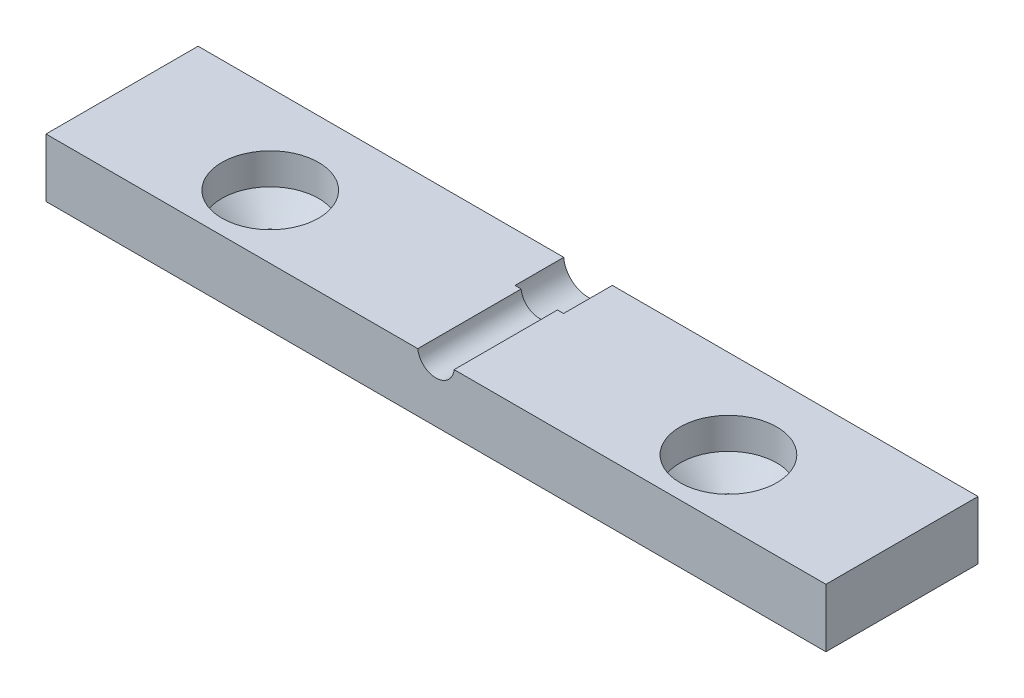
from build123d import *

# Parameters (mm, degrees)
SKETCH1_W                                    = 101.6
SKETCH1_H                                    = 19.812
BOSS_EXTRUDE1_DEPTH                          = 3.81
CSK_FOR_M6_COUNTERSUNK_FLAT_HEAD_SCR_2_COUNT = 2
CSK_FOR_M6_COUNTERSUNK_FLAT_HEAD_SCR_2_PITCH = 59.69
SKETCH5_W                                    = 101.6
SKETCH5_H                                    = 19.812
SKETCH5_R                                    = 6.3
BOSS_EXTRUDE2_DEPTH                          = 3.81
SKETCH6_R                                    = 3.175
CUT_EXTRUDE1_DEPTH                           = 6.35
CUT_EXTRUDE2_DEPTH                           = 7.35
CUT_EXTRUDE2_DEPTH_BACK                      = 14.462


with BuildPart() as part:
    # Sketch1 → Boss-Extrude1 (new body)
    with BuildSketch(Plane(origin=(0, 0, 0), x_dir=(1, 0, 0), z_dir=(0, 1, 0))):
        Rectangle(SKETCH1_W, SKETCH1_H)
    extrude(amount=BOSS_EXTRUDE1_DEPTH)

    # Sketch4 → CSK for M6 Countersunk Flat Head Screw1 (revolve, cut)
    with BuildSketch(Plane(origin=(-29.845, 3.81, 1.651), x_dir=(0, 0, 1), z_dir=(1, 0, 0))):
        Polygon((0, 0), (0, 3.81), (3.5, 3.81), (3.5, 3.054), (6.3, 0.254), (6.3, 0), align=None)
    csk_for_m6_countersunk_flat_head_screw1 = revolve(axis=Axis((-29.845, 10.16, 1.651), (0, -1, 0)), mode=Mode.SUBTRACT)

    # CSK for M6 Countersunk Flat Head Scr 2: CSK for M6 Countersunk Flat Head Screw1 ×2
    with Locations(*[(i * CSK_FOR_M6_COUNTERSUNK_FLAT_HEAD_SCR_2_PITCH, 0, 0) for i in range(1, CSK_FOR_M6_COUNTERSUNK_FLAT_HEAD_SCR_2_COUNT)]):
        add(csk_for_m6_countersunk_flat_head_screw1, mode=Mode.SUBTRACT)

    # Sketch5 → Boss-Extrude2 (add)
    with BuildSketch(Plane(origin=(0, 3.81, 0), x_dir=(1, 0, 0), z_dir=(0, 1, 0))):
        Rectangle(SKETCH5_W, SKETCH5_H)
        with Locations((-29.845, -1.651)):
            Circle(SKETCH5_R, mode=Mode.SUBTRACT)
        with Locations((29.845, -1.651)):
            Circle(SKETCH5_R, mode=Mode.SUBTRACT)
    extrude(amount=BOSS_EXTRUDE2_DEPTH)

    # Sketch6 → Cut-Extrude1 (cut)
    with BuildSketch(Plane(origin=(0, 0, -9.906), x_dir=(-1, 0, 0), z_dir=(0, 0, -1))):
        with Locations((0, 7.874)):
            Circle(SKETCH6_R)
    extrude(amount=-CUT_EXTRUDE1_DEPTH, mode=Mode.SUBTRACT)

    # Sketch7 → Cut-Extrude2 (cut, two sides)
    with BuildSketch(Plane(origin=(0, 0, -3.556), x_dir=(-1, 0, 0), z_dir=(0, 0, -1))) as cut_extrude2_sk:
        with BuildLine():
            ThreePointArc((-2.36766458, 7.62), (0, 5.49275), (2.36766458, 7.62))
            Line((2.36766458, 7.62), (-2.36766458, 7.62))
        make_face()
        with BuildLine():
            Line((-2.36766458, 7.62), (2.36766458, 7.62))
            ThreePointArc((2.36766458, 7.62), (2.377851219, 7.746818473), (2.38125, 7.874))
            ThreePointArc((2.38125, 7.874), (-0.127181527, 10.251851219), (-2.36766458, 7.62))
        make_face()
    extrude(amount=CUT_EXTRUDE2_DEPTH, mode=Mode.SUBTRACT)
    extrude(cut_extrude2_sk.sketch, amount=-CUT_EXTRUDE2_DEPTH_BACK, mode=Mode.SUBTRACT)


solid = part.part
